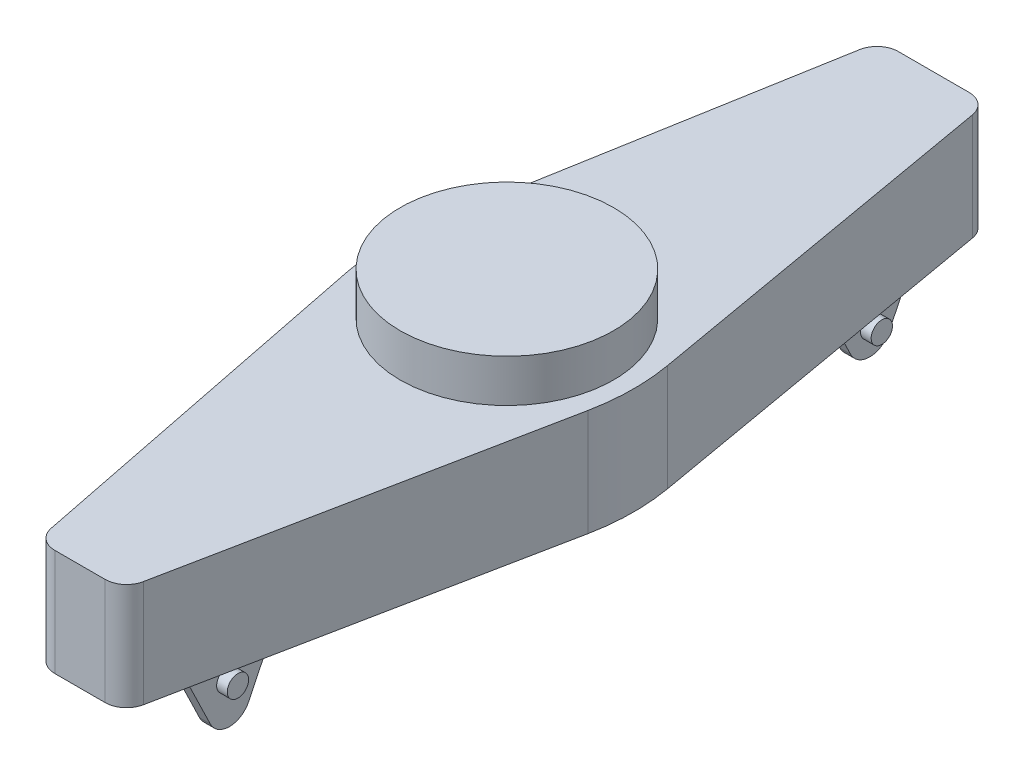
from build123d import *

# Parameters (mm, degrees)
BOSS_EXTRUDE1_DEPTH      = 25
BOSS_EXTRUDE1_DEPTH_BACK = 25
SKETCH3_R                = 50
BOSS_EXTRUDE2_DEPTH      = 45
BOSS_EXTRUDE3_DEPTH      = 5
FILLET1_R                = 100
FILLET3_R                = 10
BOSS_EXTRUDE4_DEPTH      = 5
BOSS_EXTRUDE4_DEPTH_BACK = 45
SKETCH7_R                = 5
BOSS_EXTRUDE5_DEPTH      = 5
BOSS_EXTRUDE5_DEPTH_BACK = 45
SKETCH8_R                = 5


with BuildPart() as part:
    # Sketch2 → Boss-Extrude1 (new, two sides: drawn at the far end of the back side and taken through both)
    with BuildSketch(Plane(origin=(0, 0, 0), x_dir=(1, 0, 0), z_dir=(0, 1, 0)).offset(-BOSS_EXTRUDE1_DEPTH_BACK)):
        Polygon((25, 200), (-25, 200), (-60, 0), (-20, -200), (20, -200), (60, 0), align=None)
    extrude(amount=BOSS_EXTRUDE1_DEPTH + BOSS_EXTRUDE1_DEPTH_BACK)

    # Sketch6 → Boss-Extrude3 (add)
    with BuildSketch(Plane(origin=(15, 0, 0), x_dir=(0, 0, -1), z_dir=(1, 0, 0))):
        with BuildLine():
            Line((128.903651647, -25), (140.998075731, -50))
            ThreePointArc((140.998075731, -50), (150, -55.645076413), (159.001924269, -50))
            Line((159.001924269, -50), (171.096348353, -25))
            Line((171.096348353, -25), (128.903651647, -25))
        make_face()
        with BuildLine():
            Line((-128.903651647, -25), (-140.998075731, -50))
            ThreePointArc((-140.998075731, -50), (-150, -55.645076413), (-159.001924269, -50))
            Line((-159.001924269, -50), (-171.096348353, -25))
            Line((-171.096348353, -25), (-128.903651647, -25))
        make_face()
    boss_extrude3 = extrude(amount=BOSS_EXTRUDE3_DEPTH)

    # Mirror2: Boss-Extrude3 across plane
    add(boss_extrude3.mirror(Plane(origin=(0, 0, 0), x_dir=(0, 0, 1), z_dir=(1, 0, 0))))

    # Fillet1
    fillet1_edges = [part.edges().sort_by_distance(p)[0] for p in [
        (60, 0, 0),
        (-60, 0, 0),
    ]]
    fillet(fillet1_edges, radius=FILLET1_R)

    # Fillet3
    fillet3_edges = [part.edges().sort_by_distance(p)[0] for p in [
        (20, 0, 200),
        (-20, 0, 200),
        (25, 0, -200),
        (-25, 0, -200),
    ]]
    fillet(fillet3_edges, radius=FILLET3_R)

    # Sketch7 → Boss-Extrude4 (add, two sides: drawn at the far end of the back side and taken through both)
    with BuildSketch(Plane(origin=(20, 0, 0), x_dir=(0, 0, -1), z_dir=(1, 0, 0)).offset(-BOSS_EXTRUDE4_DEPTH_BACK)):
        with Locations((-151.00257991, -36.061231276)):
            Circle(SKETCH7_R)
    extrude(amount=BOSS_EXTRUDE4_DEPTH + BOSS_EXTRUDE4_DEPTH_BACK)

    # Sketch8 → Boss-Extrude5 (add, two sides: drawn at the far end of the back side and taken through both)
    with BuildSketch(Plane(origin=(20, 0, 0), x_dir=(0, 0, -1), z_dir=(1, 0, 0)).offset(-BOSS_EXTRUDE5_DEPTH_BACK)):
        with Locations((150.672063463, -43.390539475)):
            Circle(SKETCH8_R)
    extrude(amount=BOSS_EXTRUDE5_DEPTH + BOSS_EXTRUDE5_DEPTH_BACK)


with BuildPart() as body_2:
    # Sketch3 → Boss-Extrude2 (new body)
    with BuildSketch(Plane(origin=(0, 0, 0), x_dir=(1, 0, 0), z_dir=(0, 1, 0))):
        Circle(SKETCH3_R)
    extrude(amount=BOSS_EXTRUDE2_DEPTH)


solid = Compound([part.part, body_2.part])
